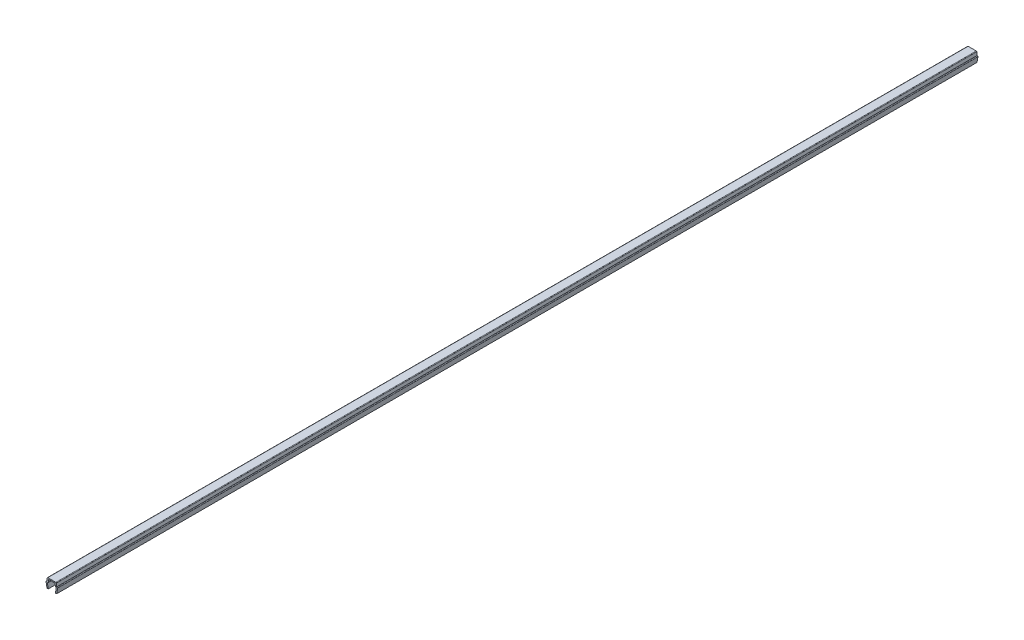
from build123d import *

# Parameters (mm, degrees)
BOSS_EXTRUDE1_DEPTH = 284.75


with BuildPart() as part:
    # Sketch1 → Boss-Extrude1 (new body, symmetric)
    with BuildSketch(Plane.XY):
        with BuildLine():
            Line((-3.6, 3.35), (-3, 0))
            Line((-3, 0), (-2.2, 0))
            Line((-2.2, 0), (-2.735217071, 2.988295315))
            ThreePointArc((-2.735217071, 2.988295315), (-2.659117427, 3.274614514), (-2.390699246, 3.4))
            Line((-2.390699246, 3.4), (-2.2, 3.4))
            Line((-2.2, 3.4), (-2.070472639, 4.88050451))
            ThreePointArc((-2.070472639, 4.88050451), (-1.958261067, 5.108047068), (-1.721804495, 5.2))
            Line((-1.721804495, 5.2), (1.721804495, 5.2))
            ThreePointArc((1.721804495, 5.2), (1.958261067, 5.108047068), (2.070472639, 4.88050451))
            Line((2.070472639, 4.88050451), (2.2, 3.4))
            Line((2.2, 3.4), (2.390699246, 3.4))
            ThreePointArc((2.390699246, 3.4), (2.659117427, 3.274614514), (2.735217071, 2.988295315))
            Line((2.735217071, 2.988295315), (2.2, 0))
            Line((2.2, 0), (3, 0))
            Line((3, 0), (3.6, 3.35))
            ThreePointArc((3.6, 3.35), (3.497487373, 3.597487373), (3.25, 3.7))
            Line((3.25, 3.7), (3, 3.7))
            Line((3, 3.7), (2.835477174, 5.58050451))
            ThreePointArc((2.835477174, 5.58050451), (2.723265602, 5.808047068), (2.486809029, 5.9))
            Line((2.486809029, 5.9), (-2.486809029, 5.9))
            ThreePointArc((-2.486809029, 5.9), (-2.723265602, 5.808047068), (-2.835477174, 5.58050451))
            Line((-2.835477174, 5.58050451), (-3, 3.7))
            Line((-3, 3.7), (-3.25, 3.7))
            ThreePointArc((-3.25, 3.7), (-3.497487373, 3.597487373), (-3.6, 3.35))
        make_face()
    extrude(amount=BOSS_EXTRUDE1_DEPTH, both=True)


solid = part.part
